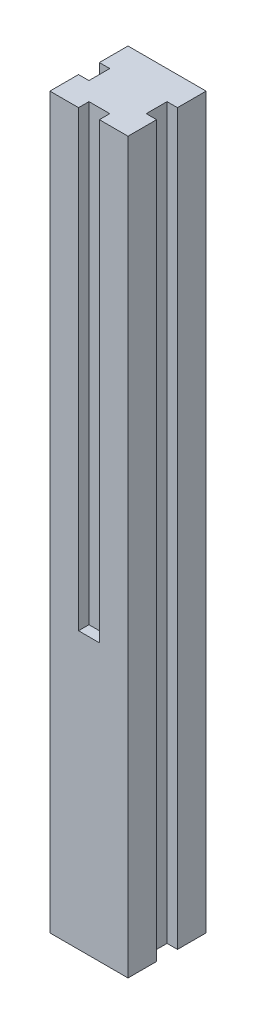
from build123d import *

# Parameters (mm, degrees)
SKETCH1_W           = 75
SKETCH1_H           = 75
BOSS_EXTRUDE1_DEPTH = 700
SKETCH2_2_W         = 20
SKETCH2_2_H         = 10
SKETCH2_2_W_2       = 10
SKETCH2_2_H_2       = 20
CUT_EXTRUDE2_DEPTH  = 435
SKETCH2_4_W         = 10
SKETCH2_4_H         = 20
CUT_EXTRUDE3_DEPTH  = 701


with BuildPart() as part:
    # Sketch1 → Boss-Extrude1 (new body)
    with BuildSketch(Plane(origin=(0, 0, 0), x_dir=(1, 0, 0), z_dir=(0, 1, 0))):
        Rectangle(SKETCH1_W, SKETCH1_H)
    extrude(amount=BOSS_EXTRUDE1_DEPTH)

    # Sketch2_2 → Cut-Extrude2 (cut)
    with BuildSketch(Plane(origin=(0, 700, 0), x_dir=(1, 0, 0), z_dir=(0, 1, 0))):
        with Locations((0, -32.5)):
            Rectangle(SKETCH2_2_W, SKETCH2_2_H)
        with Locations((-32.5, 0)):
            Rectangle(SKETCH2_2_W_2, SKETCH2_2_H_2)
    extrude(amount=-CUT_EXTRUDE2_DEPTH, mode=Mode.SUBTRACT)

    # Sketch2_4 → Cut-Extrude3 (cut, through all)
    with BuildSketch(Plane(origin=(0, 700, 0), x_dir=(1, 0, 0), z_dir=(0, 1, 0))):
        with Locations((32.5, 0)):
            Rectangle(SKETCH2_4_W, SKETCH2_4_H)
    extrude(amount=-CUT_EXTRUDE3_DEPTH, mode=Mode.SUBTRACT)


solid = part.part
